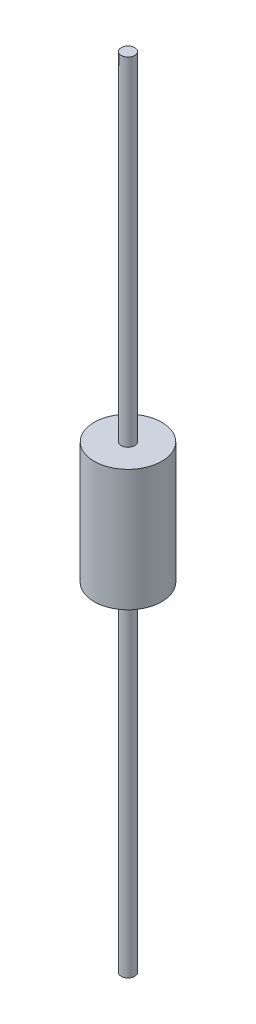
from build123d import *

# Parameters (mm, degrees)
SKETCH1_R           = 2.5
BOSS_EXTRUDE1_DEPTH = 4.5
SKETCH2_R           = 0.5
BOSS_EXTRUDE2_DEPTH = 25


with BuildPart() as part:
    # Sketch1 → Boss-Extrude1 (new body, symmetric)
    with BuildSketch(Plane(origin=(0, 0, 0), x_dir=(1, 0, 0), z_dir=(0, 1, 0))):
        Circle(SKETCH1_R)
    extrude(amount=BOSS_EXTRUDE1_DEPTH, both=True)

    # Sketch2 → Boss-Extrude2 (add)
    with BuildSketch(Plane(origin=(0, 4.5, 0), x_dir=(1, 0, 0), z_dir=(0, 1, 0))):
        Circle(SKETCH2_R)
    boss_extrude2 = extrude(amount=BOSS_EXTRUDE2_DEPTH)

    # Mirror4: Boss-Extrude2 across plane
    add(boss_extrude2.mirror(Plane.ZX))


solid = part.part
